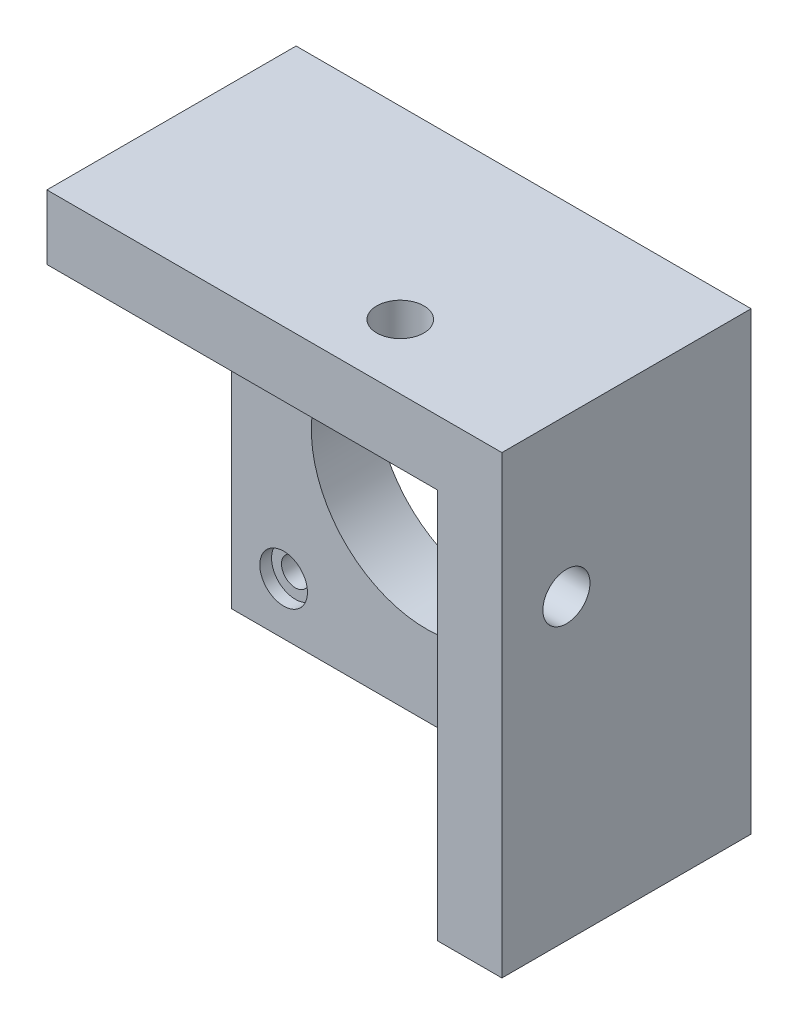
from build123d import *

# Parameters (mm, degrees)
SKETCH1_W                = 42.3
SKETCH1_H                = 42.3
BOSS_EXTRUDE1_DEPTH      = 7
SKETCH2_R                = 1.5
SKETCH2_R_2              = 12.5
CUT_EXTRUDE1_DEPTH       = 7
BOSS_EXTRUDE2_DEPTH      = 20
BOSS_EXTRUDE2_DEPTH_BACK = 7
SKETCH4_R                = 2.58
CUT_EXTRUDE2_DEPTH       = 1.27
SKETCH5_W                = 42.3
SKETCH5_H                = 7
BOSS_EXTRUDE3_DEPTH      = 20
BOSS_EXTRUDE3_DEPTH_BACK = 7
SKETCH6_R                = 2.5527
CUT_EXTRUDE3_DEPTH       = 8
SKETCH7_R                = 2.5527
CUT_EXTRUDE4_DEPTH       = 8


with BuildPart() as part:
    # Sketch1 → Boss-Extrude1 (new body)
    with BuildSketch(Plane.XY):
        Rectangle(SKETCH1_W, SKETCH1_H)
    extrude(amount=BOSS_EXTRUDE1_DEPTH)

    # Sketch2 → Cut-Extrude1 (cut)
    with BuildSketch(Plane.XY.offset(7)):
        with Locations((-15.5, 15.5)):
            Circle(SKETCH2_R)
        Circle(SKETCH2_R_2)
        with Locations((15.5, 15.5)):
            Circle(SKETCH2_R)
        with Locations((15.5, -15.5)):
            Circle(SKETCH2_R)
        with Locations((-15.5, -15.5)):
            Circle(SKETCH2_R)
    extrude(amount=-CUT_EXTRUDE1_DEPTH, mode=Mode.SUBTRACT)

    # Sketch4 → Cut-Extrude2 (cut)
    with BuildSketch(Plane.XY.offset(7)):
        with Locations((-15.5, 15.5)):
            Circle(SKETCH4_R)
        with Locations((15.5, 15.5)):
            Circle(SKETCH4_R)
        with Locations((-15.5, -15.5)):
            Circle(SKETCH4_R)
        with Locations((15.5, -15.5)):
            Circle(SKETCH4_R)
    extrude(amount=-CUT_EXTRUDE2_DEPTH, mode=Mode.SUBTRACT)


with BuildPart() as body_2:
    # Sketch3 → Boss-Extrude2 (new body, two sides)
    with BuildSketch(Plane.XY.offset(7)) as boss_extrude2_sk:
        Polygon((21.15, 21.15), (21.15, -21.15), (28.15, -21.15), (28.15, 21.15), (28.15, 28.15), (21.15, 28.15), align=None)
    extrude(amount=BOSS_EXTRUDE2_DEPTH)
    extrude(boss_extrude2_sk.sketch, amount=-BOSS_EXTRUDE2_DEPTH_BACK)

    # Sketch5 → Boss-Extrude3 (add, two sides)
    with BuildSketch(Plane.XY.offset(7)) as boss_extrude3_sk:
        with Locations((0, 24.65)):
            Rectangle(SKETCH5_W, SKETCH5_H)
    extrude(amount=BOSS_EXTRUDE3_DEPTH)
    extrude(boss_extrude3_sk.sketch, amount=-BOSS_EXTRUDE3_DEPTH_BACK)

    # Sketch6 → Cut-Extrude3 (cut, through all)
    with BuildSketch(Plane.XZ.offset(-21.15)):
        with Locations((10.15, 20.01)):
            Circle(SKETCH6_R)
    extrude(amount=-CUT_EXTRUDE3_DEPTH, mode=Mode.SUBTRACT)

    # Sketch7 → Cut-Extrude4 (cut, through all)
    with BuildSketch(Plane.ZY.offset(-21.15)):
        with Locations((20.01, 11.15)):
            Circle(SKETCH7_R)
    extrude(amount=-CUT_EXTRUDE4_DEPTH, mode=Mode.SUBTRACT)


solid = Compound([part.part, body_2.part])
